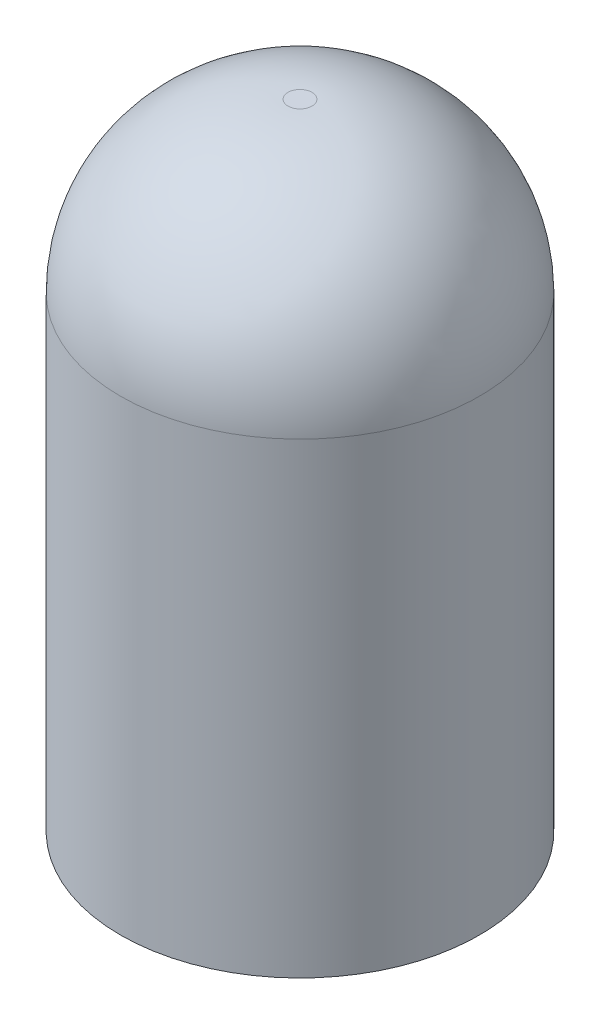
from build123d import *

# Parameters (mm, degrees)
SKETCH2_R                  = 1.5
BOSS_EXTRUDE1_DEPTH        = 5.3
FILLET1_R                  = 1.4
BOSS_EXTRUDE2_DEPTH        = 0.25
BOSS_EXTRUDE2_DEPTH_BACK   = 0.25
BOSS_EXTRUDE2_2_DEPTH      = 0.25
BOSS_EXTRUDE2_2_DEPTH_BACK = 0.25
SKETCH4_R                  = 0.2
BOSS_EXTRUDE3_DEPTH        = 0.05


with BuildPart() as part:
    # Sketch2 → Boss-Extrude1 (new body)
    with BuildSketch(Plane(origin=(0, 0, 0), x_dir=(1, 0, 0), z_dir=(0, 1, 0))):
        Circle(SKETCH2_R)
    extrude(amount=BOSS_EXTRUDE1_DEPTH)

    # Fillet1
    fillet1_edges = [part.edges().sort_by_distance(p)[0] for p in [
        (-1.5, 5.3, 0),
    ]]
    fillet(fillet1_edges, radius=FILLET1_R)



with BuildPart() as body_2:
    # Sketch3 → Boss-Extrude2 (new, two sides: drawn at the far end of the back side and taken through both)
    with BuildSketch(Plane.XY.offset(-BOSS_EXTRUDE2_DEPTH_BACK)):
        Polygon((-1.45, 2.6), (-1.45, 0), (-0.9, 0), (-0.9, 0.6), (-0.624114196, 0.6), (-0.624114196, 0.82503781), (-1.225355096, 2.6), align=None)
    extrude(amount=BOSS_EXTRUDE2_DEPTH + BOSS_EXTRUDE2_DEPTH_BACK)


with BuildPart() as body_3:
    # Sketch3 → Boss-Extrude2 2 (new, two sides: drawn at the far end of the back side and taken through both)
    with BuildSketch(Plane.XY.offset(-BOSS_EXTRUDE2_2_DEPTH_BACK)):
        Polygon((1.45, 2.6), (-0.872452828, 2.6), (0.496677266, 0.6), (0.9, 0.6), (0.9, 0), (1.45, 0), align=None)
    extrude(amount=BOSS_EXTRUDE2_2_DEPTH + BOSS_EXTRUDE2_2_DEPTH_BACK)


with BuildPart() as part_1:
    add(part.part)

    add(body_2.part)  # Boss-Extrude3 merges body 2

    add(body_3.part)  # Boss-Extrude3 merges body 3
    # Sketch4 → Boss-Extrude3 (add)
    with BuildSketch(Plane(origin=(0, 0, 0), x_dir=(-1, 0, 0), z_dir=(0, -1, 0))):
        with Locations((-1.175, 0)):
            Circle(SKETCH4_R)
        with Locations((1.175, 0)):
            Circle(SKETCH4_R)
    extrude(amount=BOSS_EXTRUDE3_DEPTH)


solid = part_1.part
